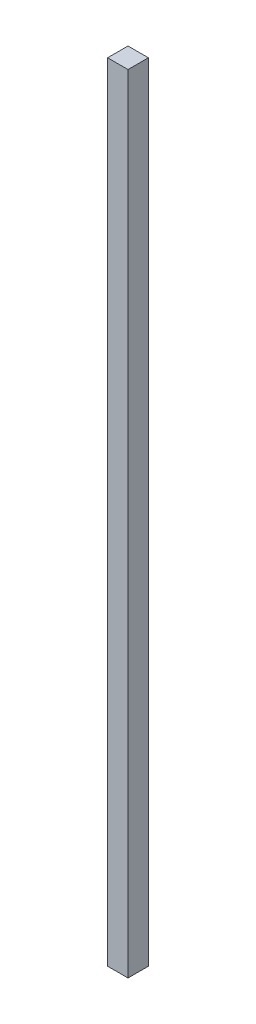
from build123d import *

# Parameters (mm, degrees)
SKETCH1_W           = 12
SKETCH1_H           = 12
BOSS_EXTRUDE1_DEPTH = 463


with BuildPart() as part:
    # Sketch1 → Boss-Extrude1 (new body)
    with BuildSketch(Plane(origin=(0, 0, 0), x_dir=(1, 0, 0), z_dir=(0, 1, 0))):
        with Locations((6, 6)):
            Rectangle(SKETCH1_W, SKETCH1_H)
    extrude(amount=BOSS_EXTRUDE1_DEPTH)


solid = part.part
